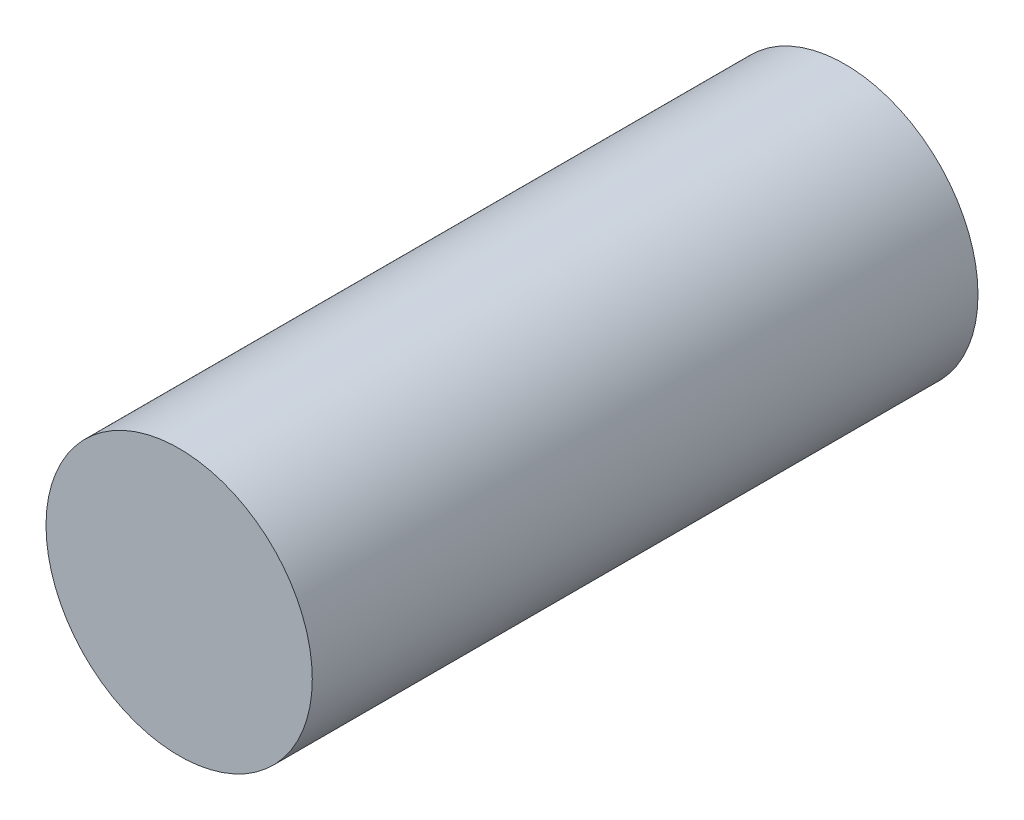
from build123d import *

# Parameters (mm, degrees)
ESQUISSE1_R        = 0.2
BOSS_EXTRU_1_DEPTH = 1


with BuildPart() as part:
    # Esquisse1 → Boss.-Extru.1 (new body)
    with BuildSketch(Plane.XY):
        Circle(ESQUISSE1_R)
    extrude(amount=BOSS_EXTRU_1_DEPTH)


solid = part.part
